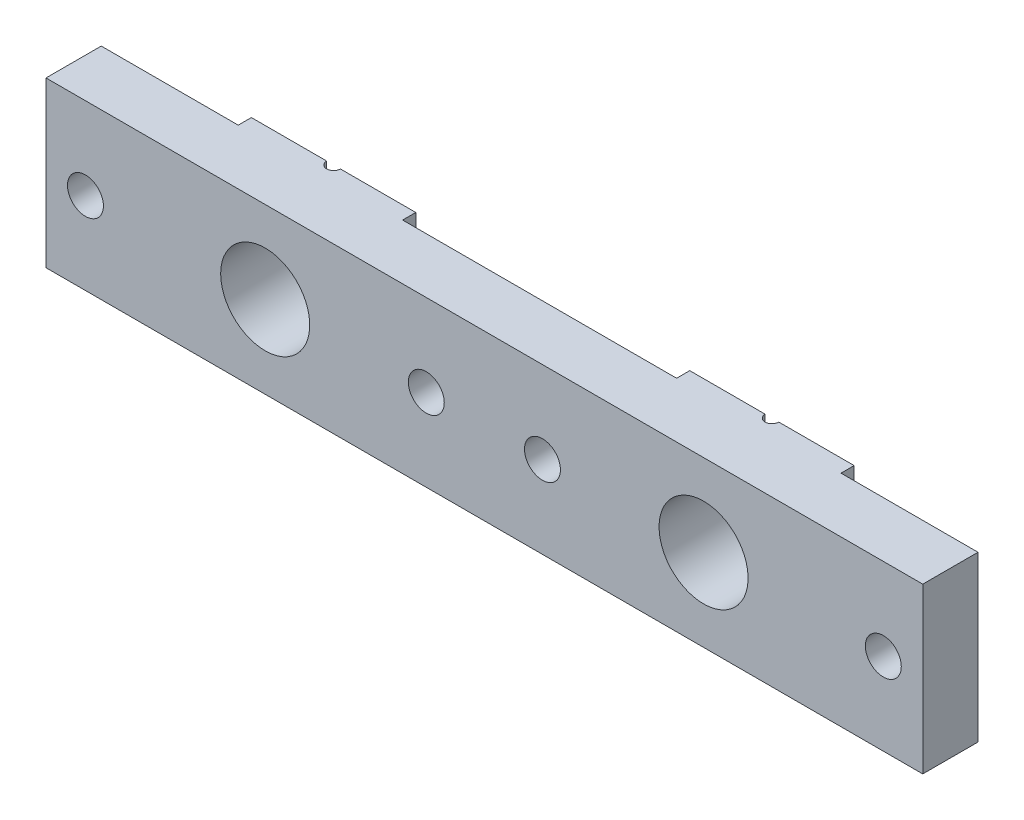
from build123d import *

# Parameters (mm, degrees)
SKETCH1_W                        = 101.6
SKETCH1_H                        = 19.05
EXTRUDE1_DEPTH                   = 7.9248
F_13_32_0_40625_DIAMETER_HOLE1_D = 10.31875
F_8_32_TAPPED_HOLE1_D            = 4.1656
SKETCH9_W                        = 31.75
SKETCH9_H                        = 19.05
SKETCH9_W_2                      = 15.875
EXTRUDE3_DEPTH                   = 1.524
F_1_16_0_0625_DIAMETER_HOLE1_D   = 1.5875


with BuildPart() as part:
    # Sketch1 → Extrude1 (new body)
    with BuildSketch(Plane.XY):
        Rectangle(SKETCH1_W, SKETCH1_H)
    extrude(amount=EXTRUDE1_DEPTH)

    # 13/32 (0.40625) Diameter Hole1 (through all)
    with Locations(Plane(origin=(0, 0, 0), x_dir=(-1, 0, 0), z_dir=(0, 0, -1))):
        with Locations((25.4, 0), (-25.4, 0)):
            Hole(F_13_32_0_40625_DIAMETER_HOLE1_D / 2)

    # #8-32 Tapped Hole1 (through all)
    with Locations(Plane.XY.offset(7.9248)):
        with Locations((-46.228, 0), (-6.731, 0), (6.731, 0), (46.228, 0)):
            Hole(F_8_32_TAPPED_HOLE1_D / 2)

    # Sketch9 → Extrude3 (cut)
    with BuildSketch(Plane(origin=(0, 0, 0), x_dir=(-1, 0, 0), z_dir=(0, 0, -1))):
        Rectangle(SKETCH9_W, SKETCH9_H)
        with Locations((-42.8625, 0)):
            Rectangle(SKETCH9_W_2, SKETCH9_H)
        with Locations((42.8625, 0)):
            Rectangle(SKETCH9_W_2, SKETCH9_H)
    extrude(amount=-EXTRUDE3_DEPTH, mode=Mode.SUBTRACT)

    # 1/16 (0.0625) Diameter Hole1 (through all)
    with Locations(Plane(origin=(0, 9.525, 0), x_dir=(-1, 0, 0), z_dir=(0, 1, 0))):
        with Locations((-25.4, 0), (25.4, 0)):
            Hole(F_1_16_0_0625_DIAMETER_HOLE1_D / 2)


solid = part.part
